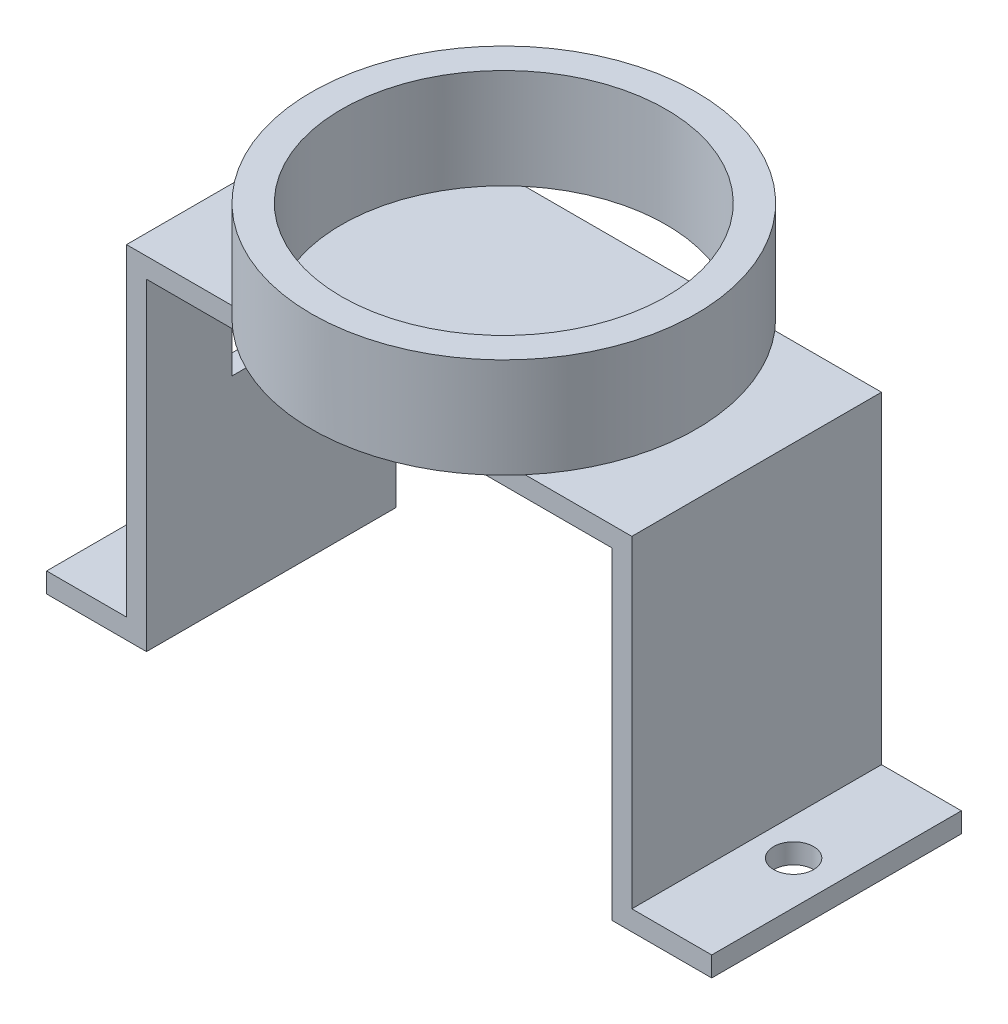
from build123d import *

# Parameters (mm, degrees)
EKSTR_ZYON_NCE1_DEPTH       = 12.5
IZIM2_R                     = 1
KES_EKSTR_ZYON1_DEPTH       = 2
IZIM3_W                     = 3.969414418
IZIM3_H                     = 2.023180186
KES_EKSTR_ZYON2_DEPTH       = 3
IZIM4_R                     = 9.625
IZIM4_R_2                   = 8.125
Y_KSEKLIK_EKSTR_ZYON1_DEPTH = 5


with BuildPart() as part:
    # Çizim1 → Ekstrüzyon-İnce1 (new body)
    with BuildSketch(Plane.XY):
        Polygon((28.3, 0), (23.3, 0), (23.3, 16.15), (0, 16.15), (0, 0), (-5, 0), (-5, 1), (-1, 1), (-1, 17.15), (24.3, 17.15), (24.3, 1), (28.3, 1), align=None)
    extrude(amount=EKSTR_ZYON_NCE1_DEPTH)

    # Çizim2 → Kes-Ekstrüzyon1 (cut, through all)
    with BuildSketch(Plane(origin=(0, 1, 0), x_dir=(1, 0, 0), z_dir=(0, 1, 0))):
        with Locations((-2.85, -6.25)):
            Circle(IZIM2_R)
        with Locations((26.15, -6.25)):
            Circle(IZIM2_R)
    extrude(amount=-KES_EKSTR_ZYON1_DEPTH, mode=Mode.SUBTRACT)

    # Çizim3 → Kes-Ekstrüzyon2 (cut)
    with BuildSketch(Plane.ZY.offset(1)):
        with Locations((6.240510002, 10.825173076)):
            Rectangle(IZIM3_W, IZIM3_H)
    extrude(amount=-KES_EKSTR_ZYON2_DEPTH, mode=Mode.SUBTRACT)

    # Çizim4 → Yükseklik-Ekstrüzyon1 (add)
    with BuildSketch(Plane(origin=(0, 17.15, 0), x_dir=(1, 0, 0), z_dir=(0, 1, 0))):
        with Locations((11.64, -6.25)):
            Circle(IZIM4_R)
        with Locations((11.64, -6.25)):
            Circle(IZIM4_R_2, mode=Mode.SUBTRACT)
    extrude(amount=Y_KSEKLIK_EKSTR_ZYON1_DEPTH)


solid = part.part
